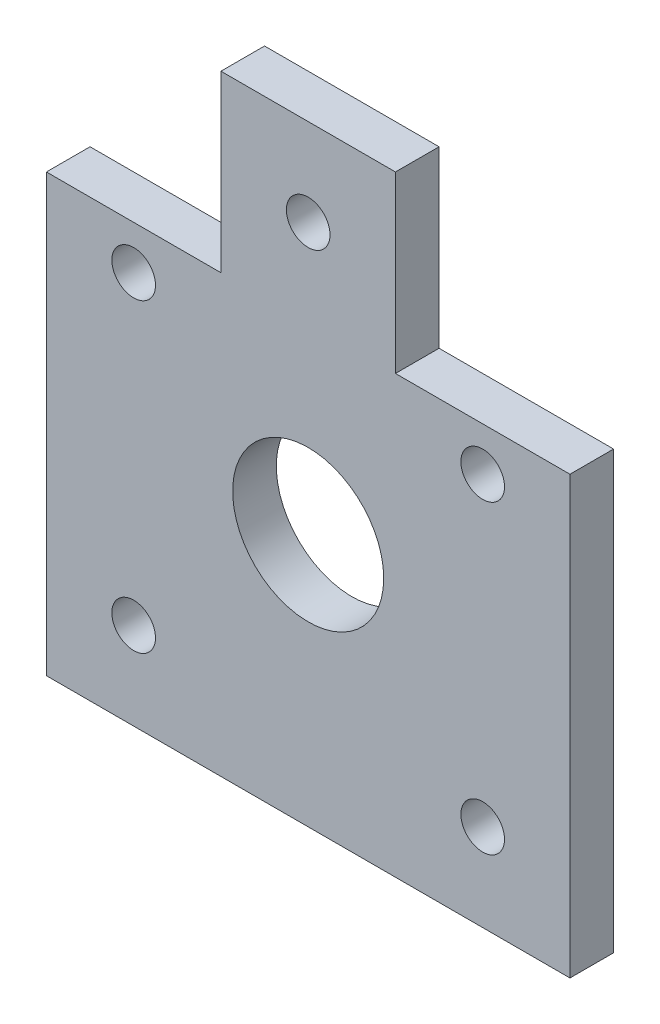
from build123d import *

# Parameters (mm, degrees)
SKETCH1_W           = 76.2
SKETCH1_H           = 88.9
BOSS_EXTRUDE1_DEPTH = 3.175
SKETCH2_R           = 3.175
SKETCH2_R_2         = 10.99185
CUT_EXTRUDE1_DEPTH  = 7.35
CUT_EXTRUDE2_REACH  = 8.35
SKETCH5_R           = 3.175
SKETCH5_W           = 25.4
SKETCH5_H           = 25.4


with BuildPart() as part:
    # Sketch1 → Boss-Extrude1 (new body, symmetric)
    with BuildSketch(Plane.XY):
        with Locations((38.1, 44.45)):
            Rectangle(SKETCH1_W, SKETCH1_H)
    extrude(amount=BOSS_EXTRUDE1_DEPTH, both=True)

    # Sketch2 → Cut-Extrude1 (cut, through all)
    with BuildSketch(Plane.XY.offset(3.175)):
        with Locations((12.7, 76.2)):
            Circle(SKETCH2_R)
        with Locations((63.5, 76.2)):
            Circle(SKETCH2_R)
        with Locations((63.5, 12.7)):
            Circle(SKETCH2_R)
        with Locations((12.7, 12.7)):
            Circle(SKETCH2_R)
        with Locations((38.1, 36.83)):
            Circle(SKETCH2_R_2)
        with Locations((12.7, 57.15)):
            Circle(SKETCH2_R)
        with Locations((63.5, 57.15)):
            Circle(SKETCH2_R)
    extrude(amount=-CUT_EXTRUDE1_DEPTH, mode=Mode.SUBTRACT)

    # Sketch5 → Cut-Extrude2 (cut, up to next)
    with BuildSketch(Plane.XY.offset(3.175), mode=Mode.PRIVATE) as cut_extrude2_sk1:
        with Locations((38.1, 76.2)):
            Circle(SKETCH5_R)
    cut_extrude2_tool1 = extrude(cut_extrude2_sk1.sketch, amount=-CUT_EXTRUDE2_REACH, mode=Mode.PRIVATE) & part.part
    add(cut_extrude2_tool1.solids().sort_by_distance((38.1, 76.2, 3.175))[0], mode=Mode.SUBTRACT)
    # Sketch5 → Cut-Extrude2 (cut, up to next)
    with BuildSketch(Plane.XY.offset(3.175), mode=Mode.PRIVATE) as cut_extrude2_sk2:
        with Locations((63.5, 76.2)):
            Rectangle(SKETCH5_W, SKETCH5_H)
    cut_extrude2_tool2 = extrude(cut_extrude2_sk2.sketch, amount=-CUT_EXTRUDE2_REACH, mode=Mode.PRIVATE) & part.part
    add(cut_extrude2_tool2.solids().sort_by_distance((63.5, 76.2, 3.175))[0], mode=Mode.SUBTRACT)
    # Sketch5 → Cut-Extrude2 (cut, up to next)
    with BuildSketch(Plane.XY.offset(3.175), mode=Mode.PRIVATE) as cut_extrude2_sk3:
        with Locations((12.7, 76.2)):
            Rectangle(SKETCH5_W, SKETCH5_H)
    cut_extrude2_tool3 = extrude(cut_extrude2_sk3.sketch, amount=-CUT_EXTRUDE2_REACH, mode=Mode.PRIVATE) & part.part
    add(cut_extrude2_tool3.solids().sort_by_distance((12.7, 76.2, 3.175))[0], mode=Mode.SUBTRACT)


solid = part.part
